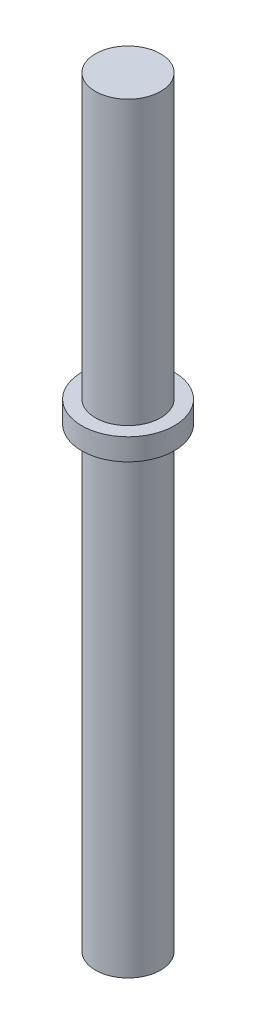
from build123d import *

# Parameters (mm, degrees)
SKETCH1_R           = 1.5
BOSS_EXTRUDE1_DEPTH = 35
SKETCH4_R           = 2.129761361
BOSS_EXTRUDE2_DEPTH = 1


with BuildPart() as part:
    # Sketch1 → Boss-Extrude1 (new body)
    with BuildSketch(Plane(origin=(0, 0, 0), x_dir=(1, 0, 0), z_dir=(0, 1, 0))):
        Circle(SKETCH1_R)
    extrude(amount=BOSS_EXTRUDE1_DEPTH)

    # Sketch4 → Boss-Extrude2 (add)
    with BuildSketch(Plane(origin=(0, 21, 0), x_dir=(-1, 0, 0), z_dir=(0, -1, 0))):
        Circle(SKETCH4_R)
    extrude(amount=-BOSS_EXTRUDE2_DEPTH)


solid = part.part
